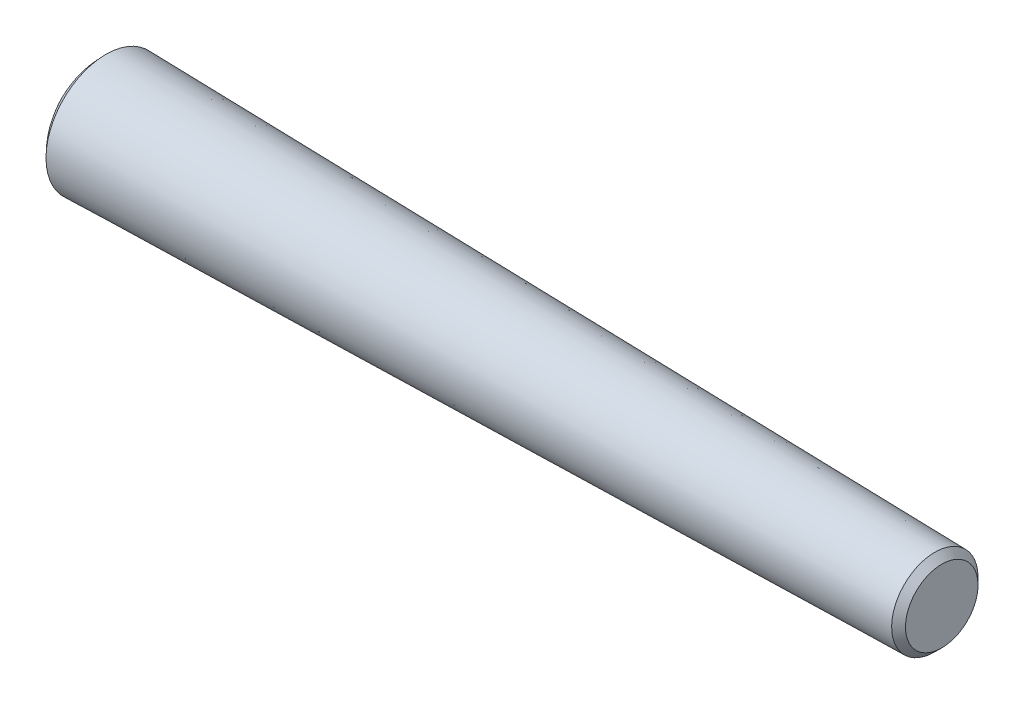
from build123d import *


with BuildPart() as part:
    # Sketch1 → Revolve2 (revolve)
    with BuildSketch(Plane.XY):
        with BuildLine():
            Line((0, 0.865887785), (12, 0.625))
            Line((12, 0.625), (12.1, 0.525))
            Line((12.1, 0.525), (12.1, 0))
            Line((12.1, 0), (-0.36919416, 0))
            ThreePointArc((-0.36919416, 0), (-0.273043563, 0.47065539), (0, 0.865887785))
        make_face()
    revolve(axis=Axis((-0.36919416, 0, 0), (1, 0, 0)))


solid = part.part
